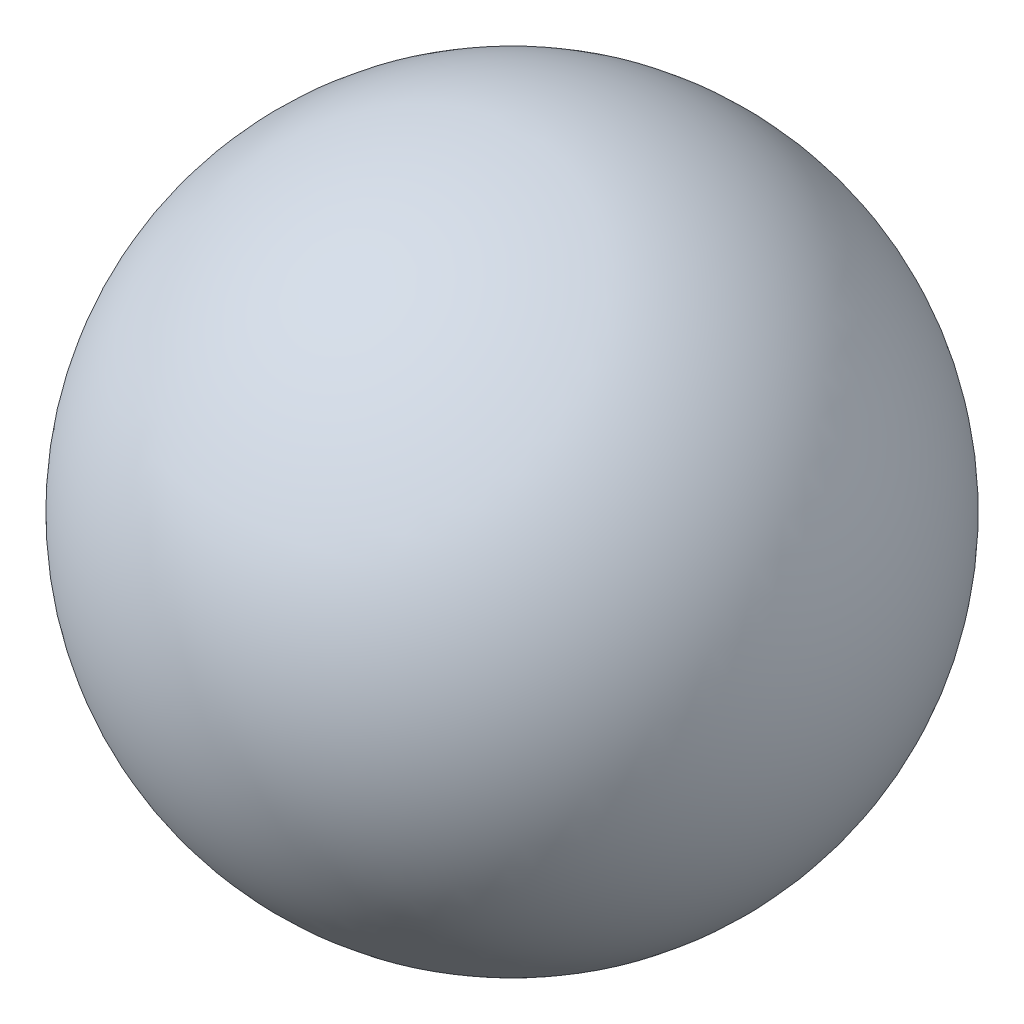
from build123d import *


with BuildPart() as part:
    # Sketch1 one side → Revolve1 (revolve)
    with BuildSketch(Plane.XY):
        with BuildLine():
            ThreePointArc((0, -6.35), (4.490128061, -4.490128061), (6.35, 0))
            ThreePointArc((6.35, 0), (4.490128061, 4.490128061), (0, 6.35))
            Line((0, 6.35), (0, -6.35))
        make_face()
    revolve(axis=Axis((0, 6.35, 0), (0, -1, 0)))


solid = part.part
